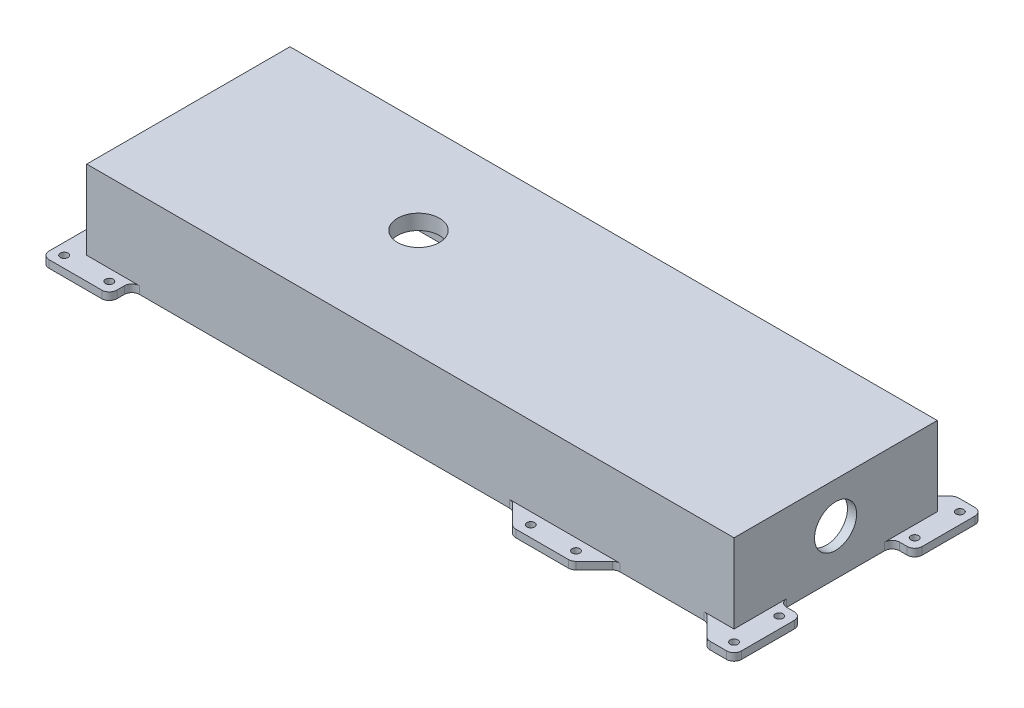
from build123d import *

# Parameters (mm, degrees)
SKETCH1_W           = 546.1
SKETCH1_H           = 171.45
BOSS_EXTRUDE1_DEPTH = 73.025
CUT_EXTRUDE1_DEPTH  = 60.325
CUT_EXTRUDE2_REACH  = 75.025
SKETCH5_R           = 17.749738032
CUT_EXTRUDE3_REACH  = 548.1
SKETCH6_R           = 17.749738032
CHAMFER1_SIZE       = 0.635
SKETCH7_R           = 3.2639
BOSS_EXTRUDE4_DEPTH = 6.35


with BuildPart() as part:
    # Sketch1 → Boss-Extrude1 (new body)
    with BuildSketch(Plane(origin=(0, 0, 0), x_dir=(1, 0, 0), z_dir=(0, 1, 0))):
        Rectangle(SKETCH1_W, SKETCH1_H)
    extrude(amount=BOSS_EXTRUDE1_DEPTH)

    # Sketch2 → Cut-Extrude1 (cut)
    with BuildSketch(Plane.XZ):
        with BuildLine():
            Line((220.748619551, 78.012946552), (-220.748619551, 78.012946552))
            ThreePointArc((-220.748619551, 78.012946552), (-252.278035042, 64.953035042), (-265.337946552, 33.423619551))
            Line((-265.337946552, 33.423619551), (-265.337946552, -33.423619551))
            ThreePointArc((-265.337946552, -33.423619551), (-252.278035042, -64.953035042), (-220.748619551, -78.012946552))
            Line((-220.748619551, -78.012946552), (220.748619551, -78.012946552))
            ThreePointArc((220.748619551, -78.012946552), (252.278035042, -64.953035042), (265.337946552, -33.423619551))
            Line((265.337946552, -33.423619551), (265.337946552, 33.423619551))
            ThreePointArc((265.337946552, 33.423619551), (252.278035042, 64.953035042), (220.748619551, 78.012946552))
        make_face()
    extrude(amount=-CUT_EXTRUDE1_DEPTH, mode=Mode.SUBTRACT)

    # Sketch5 → Cut-Extrude2 (cut, up to next)
    with BuildSketch(Plane(origin=(0, 73.025, 0), x_dir=(1, 0, 0), z_dir=(0, 1, 0)), mode=Mode.PRIVATE) as cut_extrude2_sk1:
        with Locations((-84.700666343, 5.811180929)):
            Circle(SKETCH5_R)
    cut_extrude2_tool1 = extrude(cut_extrude2_sk1.sketch, amount=-CUT_EXTRUDE2_REACH, mode=Mode.PRIVATE) & part.part
    add(cut_extrude2_tool1.solids().sort_by_distance((-84.700666, 73.025, -5.811181))[0], mode=Mode.SUBTRACT)

    # Sketch6 → Cut-Extrude3 (cut, up to next)
    with BuildSketch(Plane(origin=(273.05, 0, 0), x_dir=(0, 0, -1), z_dir=(1, 0, 0)), mode=Mode.PRIVATE) as cut_extrude3_sk1:
        with Locations((-0.077641224, 38.739963406)):
            Circle(SKETCH6_R)
    cut_extrude3_tool1 = extrude(cut_extrude3_sk1.sketch, amount=-CUT_EXTRUDE3_REACH, mode=Mode.PRIVATE) & part.part
    add(cut_extrude3_tool1.solids().sort_by_distance((273.05, 38.739963, 0.077641))[0], mode=Mode.SUBTRACT)

    # Chamfer1
    chamfer1_edges = [part.edges().sort_by_distance(p)[0] for p in [
        (252.278035042, 0, 64.953035042),
        (252.278035042, 0, -64.953035042),
        (-252.278035042, 0, -64.953035042),
        (0, 0, 78.012946552),
        (-252.278035042, 0, 64.953035042),
        (-265.337946552, 0, 0),
        (0, 0, -78.012946552),
        (265.337946552, 0, 0),
    ]]
    chamfer(chamfer1_edges, length=CHAMFER1_SIZE)

    # Sketch7 → Boss-Extrude4 (add)
    with BuildSketch(Plane.XZ):
        with BuildLine():
            ThreePointArc((-279.4, 47.625), (-274.909871939, 45.765128061), (-273.05, 41.275))
            Line((-273.05, 41.275), (-273.05, 85.725))
            Line((-273.05, 85.725), (-228.6, 85.725))
            ThreePointArc((-228.6, 85.725), (-233.090128061, 87.584871939), (-234.95, 92.075))
            Line((-234.95, 92.075), (-234.95, 98.425))
            ThreePointArc((-234.95, 98.425), (-236.809871939, 102.915128061), (-241.3, 104.775))
            Line((-241.3, 104.775), (-285.75, 104.775))
            ThreePointArc((-285.75, 104.775), (-290.240128061, 102.915128061), (-292.1, 98.425))
            Line((-292.1, 98.425), (-292.1, 53.975))
            ThreePointArc((-292.1, 53.975), (-290.240128061, 49.484871939), (-285.75, 47.625))
            Line((-285.75, 47.625), (-279.4, 47.625))
        make_face()
        with Locations((-282.575, 57.15)):
            Circle(SKETCH7_R, mode=Mode.SUBTRACT)
        with Locations((-282.575, 95.25)):
            Circle(SKETCH7_R, mode=Mode.SUBTRACT)
        with Locations((-244.475, 95.25)):
            Circle(SKETCH7_R, mode=Mode.SUBTRACT)
        with BuildLine():
            ThreePointArc((88.129615818, 87.584871939), (86.069527553, 86.208364969), (83.639487758, 85.725))
            Line((83.639487758, 85.725), (176.710512242, 85.725))
            ThreePointArc((176.710512242, 85.725), (174.280472447, 86.208364969), (172.220384182, 87.584871939))
            Line((172.220384182, 87.584871939), (156.890128061, 102.915128061))
            ThreePointArc((156.890128061, 102.915128061), (154.830039796, 104.291635031), (152.4, 104.775))
            Line((152.4, 104.775), (107.95, 104.775))
            ThreePointArc((107.95, 104.775), (105.519960204, 104.291635031), (103.459871939, 102.915128061))
            Line((103.459871939, 102.915128061), (88.129615818, 87.584871939))
        make_face()
        with Locations((111.125, 95.25)):
            Circle(SKETCH7_R, mode=Mode.SUBTRACT)
        with Locations((149.225, 95.25)):
            Circle(SKETCH7_R, mode=Mode.SUBTRACT)
        with BuildLine():
            ThreePointArc((252.140128061, 87.584871939), (250.080039796, 86.208364969), (247.65, 85.725))
            Line((247.65, 85.725), (273.05, 85.725))
            Line((273.05, 85.725), (273.05, 41.275))
            ThreePointArc((273.05, 41.275), (274.909871939, 45.765128061), (279.4, 47.625))
            Line((279.4, 47.625), (285.75, 47.625))
            ThreePointArc((285.75, 47.625), (290.240128061, 49.484871939), (292.1, 53.975))
            Line((292.1, 53.975), (292.1, 98.425))
            ThreePointArc((292.1, 98.425), (290.240128061, 102.915128061), (285.75, 104.775))
            Line((285.75, 104.775), (271.960512242, 104.775))
            ThreePointArc((271.960512242, 104.775), (269.530472447, 104.291635031), (267.470384182, 102.915128061))
            Line((267.470384182, 102.915128061), (252.140128061, 87.584871939))
        make_face()
        with Locations((282.575, 57.15)):
            Circle(SKETCH7_R, mode=Mode.SUBTRACT)
        with Locations((282.575, 95.25)):
            Circle(SKETCH7_R, mode=Mode.SUBTRACT)
        with BuildLine():
            Line((273.05, -85.725), (247.65, -85.725))
            ThreePointArc((247.65, -85.725), (250.080039796, -86.208364969), (252.140128061, -87.584871939))
            Line((252.140128061, -87.584871939), (267.470384182, -102.915128061))
            ThreePointArc((267.470384182, -102.915128061), (269.530472447, -104.291635031), (271.960512242, -104.775))
            Line((271.960512242, -104.775), (285.75, -104.775))
            ThreePointArc((285.75, -104.775), (290.240128061, -102.915128061), (292.1, -98.425))
            Line((292.1, -98.425), (292.1, -53.975))
            ThreePointArc((292.1, -53.975), (290.240128061, -49.484871939), (285.75, -47.625))
            Line((285.75, -47.625), (279.4, -47.625))
            ThreePointArc((279.4, -47.625), (274.909871939, -45.765128061), (273.05, -41.275))
            Line((273.05, -41.275), (273.05, -85.725))
        make_face()
        with Locations((282.575, -95.25)):
            Circle(SKETCH7_R, mode=Mode.SUBTRACT)
        with Locations((282.575, -57.15)):
            Circle(SKETCH7_R, mode=Mode.SUBTRACT)
        with BuildLine():
            Line((176.710512242, -85.725), (83.639487758, -85.725))
            ThreePointArc((83.639487758, -85.725), (86.069527553, -86.208364969), (88.129615818, -87.584871939))
            Line((88.129615818, -87.584871939), (103.459871939, -102.915128061))
            ThreePointArc((103.459871939, -102.915128061), (105.519960204, -104.291635031), (107.95, -104.775))
            Line((107.95, -104.775), (152.4, -104.775))
            ThreePointArc((152.4, -104.775), (154.830039796, -104.291635031), (156.890128061, -102.915128061))
            Line((156.890128061, -102.915128061), (172.220384182, -87.584871939))
            ThreePointArc((172.220384182, -87.584871939), (174.280472447, -86.208364969), (176.710512242, -85.725))
        make_face()
        with Locations((111.125, -95.25)):
            Circle(SKETCH7_R, mode=Mode.SUBTRACT)
        with Locations((149.225, -95.25)):
            Circle(SKETCH7_R, mode=Mode.SUBTRACT)
        with BuildLine():
            Line((-228.6, -85.725), (-273.05, -85.725))
            Line((-273.05, -85.725), (-273.05, -41.275))
            ThreePointArc((-273.05, -41.275), (-274.909871939, -45.765128061), (-279.4, -47.625))
            Line((-279.4, -47.625), (-285.75, -47.625))
            ThreePointArc((-285.75, -47.625), (-290.240128061, -49.484871939), (-292.1, -53.975))
            Line((-292.1, -53.975), (-292.1, -98.425))
            ThreePointArc((-292.1, -98.425), (-290.240128061, -102.915128061), (-285.75, -104.775))
            Line((-285.75, -104.775), (-241.3, -104.775))
            ThreePointArc((-241.3, -104.775), (-236.809871939, -102.915128061), (-234.95, -98.425))
            Line((-234.95, -98.425), (-234.95, -92.075))
            ThreePointArc((-234.95, -92.075), (-233.090128061, -87.584871939), (-228.6, -85.725))
        make_face()
        with Locations((-282.575, -95.25)):
            Circle(SKETCH7_R, mode=Mode.SUBTRACT)
        with Locations((-244.475, -95.25)):
            Circle(SKETCH7_R, mode=Mode.SUBTRACT)
        with Locations((-282.575, -57.15)):
            Circle(SKETCH7_R, mode=Mode.SUBTRACT)
    extrude(amount=-BOSS_EXTRUDE4_DEPTH)


solid = part.part
